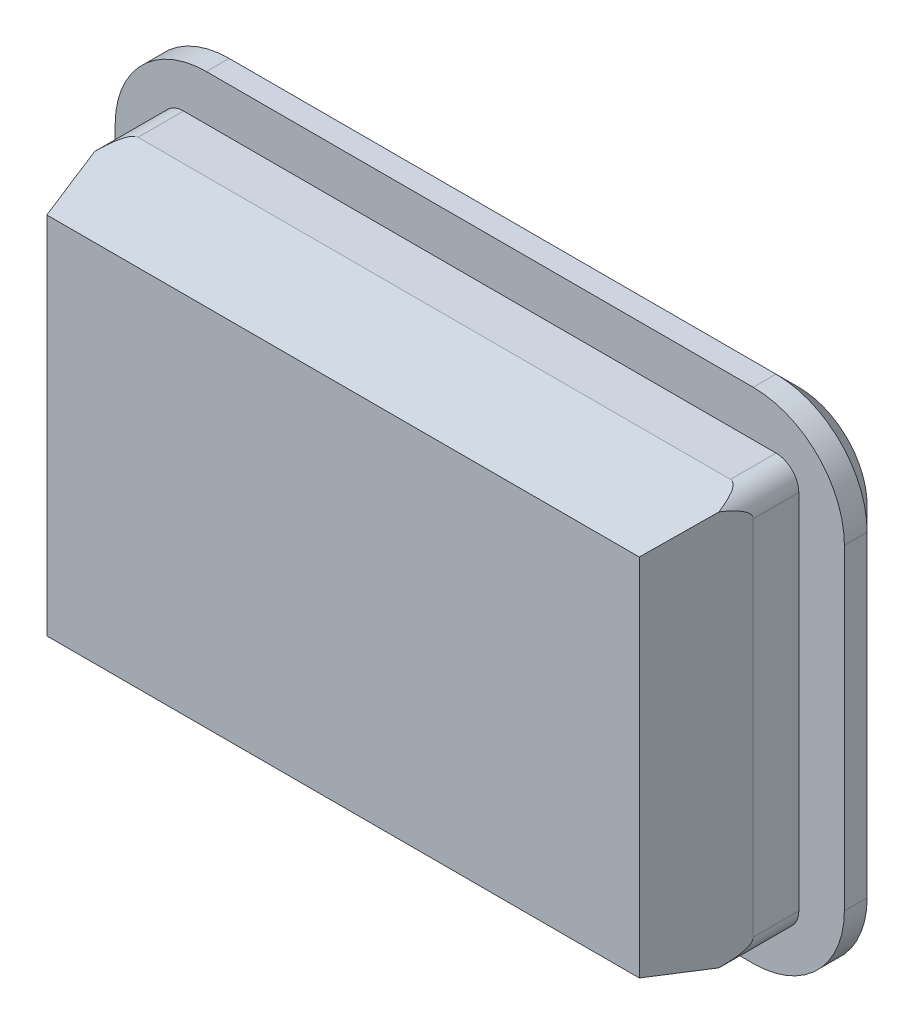
from build123d import *

# Parameters (mm, degrees)
SKETCH2_W           = 13
SKETCH2_H           = 8
SKETCH1_W           = 14
SKETCH1_H           = 8.95
SKETCH3_W           = 14
SKETCH3_H           = 8.95
BOSS_EXTRUDE1_DEPTH = 1
SKETCH4_W           = 16
SKETCH4_H           = 10.95
BOSS_EXTRUDE2_DEPTH = 1
FILLET1_R           = 2
CHAMFER1_SIZE       = 0.5
FILLET2_R           = 0.5


with BuildPart() as part:
    # Sketch2 → Loft1 section 0
    with BuildSketch(Plane.XY.offset(2)):
        Rectangle(SKETCH2_W, SKETCH2_H)
    # Sketch1 → Loft1 section 1
    with BuildSketch(Plane.XY):
        Rectangle(SKETCH1_W, SKETCH1_H)
    loft()

    # Sketch3 → Boss-Extrude1 (add)
    with BuildSketch(Plane(origin=(0, 0, 0), x_dir=(-1, 0, 0), z_dir=(0, 0, -1))):
        Rectangle(SKETCH3_W, SKETCH3_H)
    extrude(amount=BOSS_EXTRUDE1_DEPTH)

    # Sketch4 → Boss-Extrude2 (add)
    with BuildSketch(Plane(origin=(0, 0, -1), x_dir=(-1, 0, 0), z_dir=(0, 0, -1))):
        Rectangle(SKETCH4_W, SKETCH4_H)
    extrude(amount=BOSS_EXTRUDE2_DEPTH)

    # Fillet1
    fillet1_edges = [part.edges().sort_by_distance(p)[0] for p in [
        (-8, -5.475, -1.5),
        (-8, 5.475, -1.5),
        (8, 5.475, -1.5),
        (8, -5.475, -1.5),
    ]]
    fillet(fillet1_edges, radius=FILLET1_R)

    # Chamfer1
    chamfer1_edges = [part.edges().sort_by_distance(p)[0] for p in [
        (-8, 0, -2),
        (0, -5.475, -2),
        (0, 5.475, -2),
        (8, 0, -2),
        (7.414213562, 4.889213562, -2),
        (7.414213562, -4.889213562, -2),
        (-7.414213562, 4.889213562, -2),
        (-7.414213562, -4.889213562, -2),
    ]]
    chamfer(chamfer1_edges, length=CHAMFER1_SIZE)

    # Fillet2
    fillet2_edges = [part.edges().sort_by_distance(p)[0] for p in [
        (-7, -4.475, -0.5),
        (-7, 4.475, -0.5),
        (7, -4.475, -0.5),
        (7, 4.475, -0.5),
    ]]
    fillet(fillet2_edges, radius=FILLET2_R)


solid = part.part
